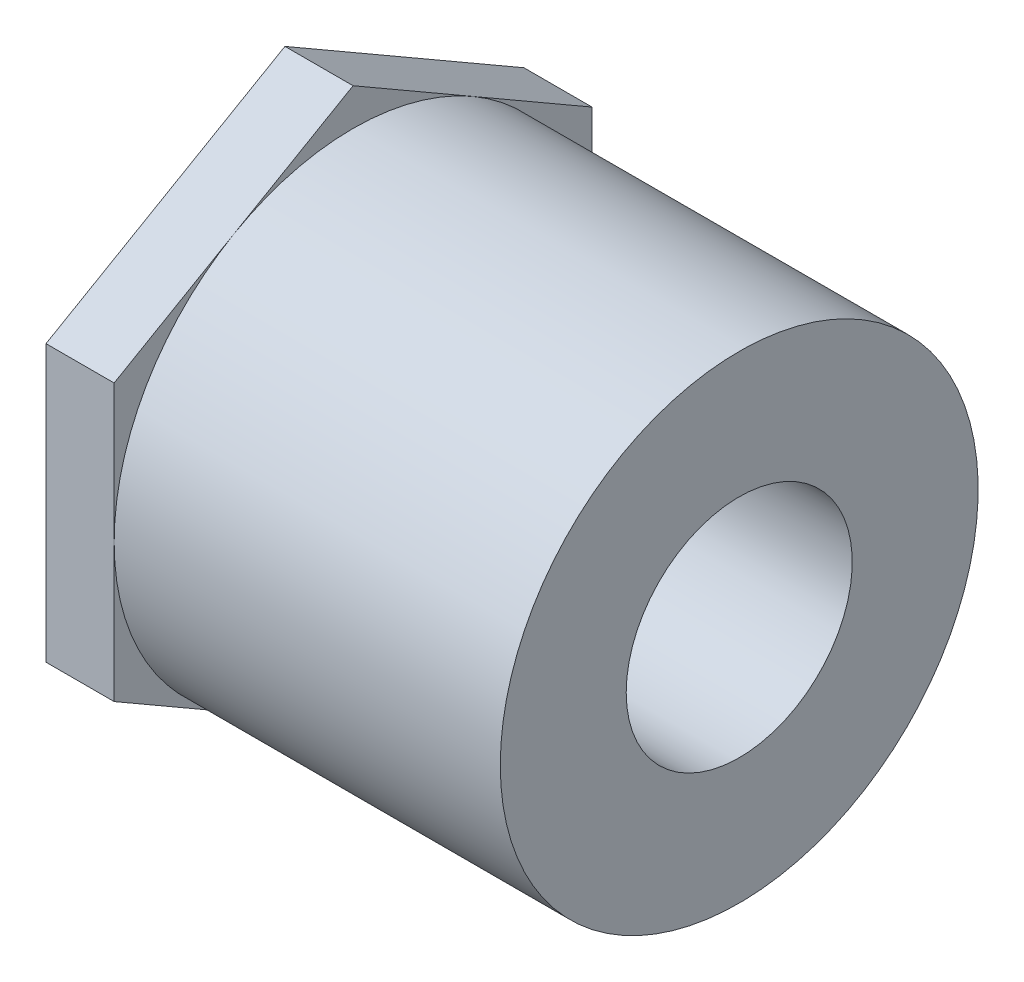
from build123d import *

# Parameters (mm, degrees)
SKETCH2_R           = 10.7696
BOSS_EXTRUDE1_DEPTH = 4.7625


with BuildPart() as part:
    # Sketch1 → Revolve1 (revolve)
    with BuildSketch(Plane.XY):
        Polygon((-31.75, -16.7005), (0, -16.7005), (0, -7.8994), (-11.90625, -7.8994), (-11.90625, -10.6172), (-31.75, -10.7696), align=None)
    revolve(axis=Axis((-31.75, 0, 0), (1, 0, 0)))

    # Sketch2 → Boss-Extrude1 (add)
    with BuildSketch(Plane.ZY.offset(31.75)):
        Polygon((0, 19.284076341), (-16.7005, 9.642038171), (-16.7005, -9.642038171), (0, -19.284076341), (16.7005, -9.642038171), (16.7005, 9.642038171), align=None)
        Circle(SKETCH2_R, mode=Mode.SUBTRACT)
    extrude(amount=-BOSS_EXTRUDE1_DEPTH)


solid = part.part
